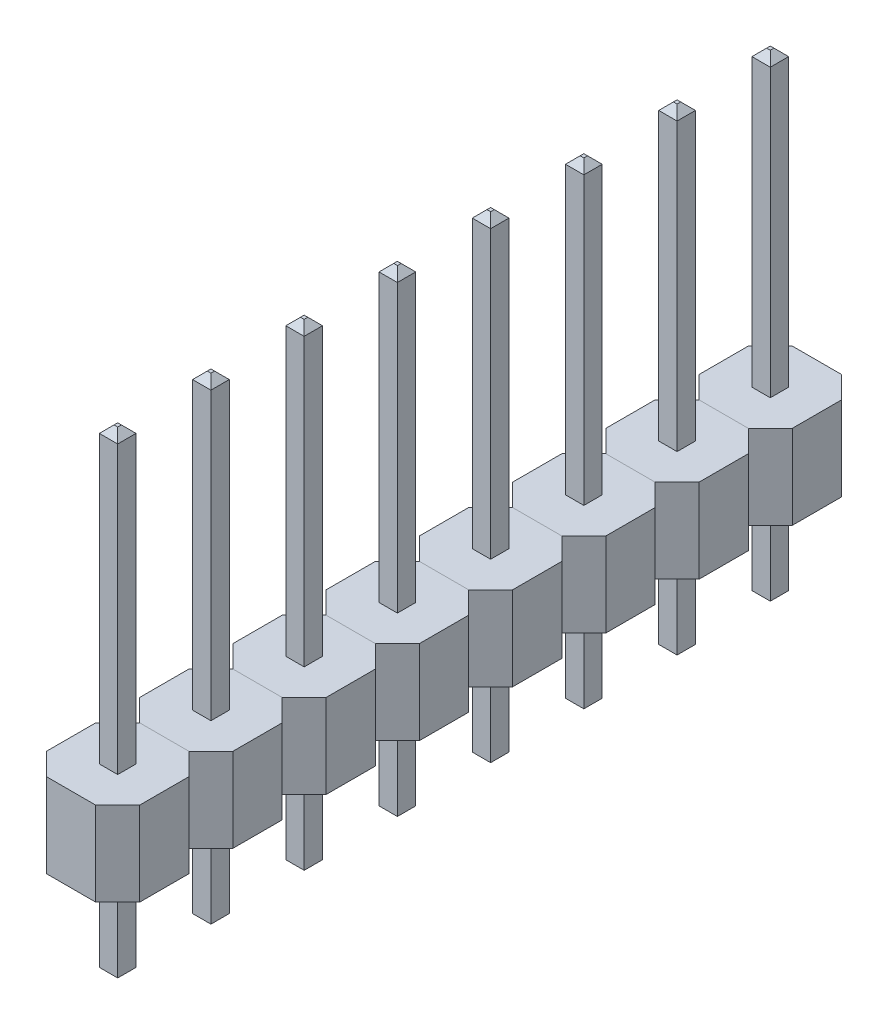
from build123d import *

# Parameters (mm, degrees)
SKETCH1_W                = 2.54
SKETCH1_H                = 2.54
BOSS_EXTRUDE1_DEPTH      = 2.29
CHAMFER1_SIZE            = 0.6
BOSS_EXTRUDE2_DEPTH      = 8
BOSS_EXTRUDE2_DEPTH_BACK = 5
SKETCH2_W                = 0.5
SKETCH2_H                = 0.5
CHAMFER2_SIZE            = 0.2
PATTERN_LINEAR_2_COUNT   = 8
PATTERN_LINEAR_2_PITCH   = 2.54


with BuildPart() as part:
    # Sketch1 → Boss-Extrude1 (new body)
    with BuildSketch(Plane(origin=(0, 0, 0), x_dir=(1, 0, 0), z_dir=(0, 1, 0))):
        Rectangle(SKETCH1_W, SKETCH1_H)
    extrude(amount=BOSS_EXTRUDE1_DEPTH)

    # Chamfer1
    chamfer1_edges = [part.edges().sort_by_distance(p)[0] for p in [
        (-1.27, 1.145, -1.27),
        (1.27, 1.145, -1.27),
        (1.27, 1.145, 1.27),
        (-1.27, 1.145, 1.27),
    ]]
    chamfer(chamfer1_edges, length=CHAMFER1_SIZE)

    # Sketch2 → Boss-Extrude2 (add, two sides: drawn at the far end of the back side and taken through both)
    with BuildSketch(Plane(origin=(0, 2.29, 0), x_dir=(1, 0, 0), z_dir=(0, 1, 0)).offset(-BOSS_EXTRUDE2_DEPTH_BACK)):
        Rectangle(SKETCH2_W, SKETCH2_H)
    extrude(amount=BOSS_EXTRUDE2_DEPTH + BOSS_EXTRUDE2_DEPTH_BACK)

    # Chamfer2
    chamfer2_edges = [part.edges().sort_by_distance(p)[0] for p in [
        (0, 10.29, 0.25),
        (-0.25, 10.29, 0),
        (0, 10.29, -0.25),
        (0.25, 10.29, 0),
        (0, -2.71, -0.25),
        (-0.25, -2.71, 0),
        (0, -2.71, 0.25),
        (0.25, -2.71, 0),
    ]]
    chamfer(chamfer2_edges, length=CHAMFER2_SIZE)


with BuildPart() as pattern_linear_2_1:
    # Линейный массив2: pattern copy
    add(part.part.moved(Location(Vector(0, 0, 1) * (1 * PATTERN_LINEAR_2_PITCH))))


with BuildPart() as pattern_linear_2_2:
    # Линейный массив2: pattern copy
    add(part.part.moved(Location(Vector(0, 0, 1) * (2 * PATTERN_LINEAR_2_PITCH))))


with BuildPart() as pattern_linear_2_3:
    # Линейный массив2: pattern copy
    add(part.part.moved(Location(Vector(0, 0, 1) * (3 * PATTERN_LINEAR_2_PITCH))))


with BuildPart() as pattern_linear_2_4:
    # Линейный массив2: pattern copy
    add(part.part.moved(Location(Vector(0, 0, 1) * (4 * PATTERN_LINEAR_2_PITCH))))


with BuildPart() as pattern_linear_2_5:
    # Линейный массив2: pattern copy
    add(part.part.moved(Location(Vector(0, 0, 1) * (5 * PATTERN_LINEAR_2_PITCH))))


with BuildPart() as pattern_linear_2_6:
    # Линейный массив2: pattern copy
    add(part.part.moved(Location(Vector(0, 0, 1) * (6 * PATTERN_LINEAR_2_PITCH))))


with BuildPart() as pattern_linear_2_7:
    # Линейный массив2: pattern copy
    add(part.part.moved(Location(Vector(0, 0, 1) * (7 * PATTERN_LINEAR_2_PITCH))))


solid = Compound([part.part, pattern_linear_2_1.part, pattern_linear_2_2.part, pattern_linear_2_3.part, pattern_linear_2_4.part, pattern_linear_2_5.part, pattern_linear_2_6.part, pattern_linear_2_7.part])
